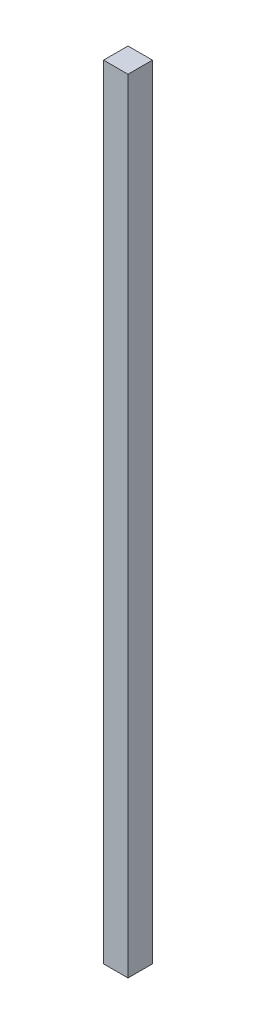
from build123d import *

# Parameters (mm, degrees)
SKETCH1_W           = 38.1
SKETCH1_H           = 38.1
BOSS_EXTRUDE1_DEPTH = 1219.2


with BuildPart() as part:
    # Sketch1 → Boss-Extrude1 (new body)
    with BuildSketch(Plane(origin=(0, 0, 0), x_dir=(1, 0, 0), z_dir=(0, 1, 0))):
        Rectangle(SKETCH1_W, SKETCH1_H)
    extrude(amount=BOSS_EXTRUDE1_DEPTH)


solid = part.part
